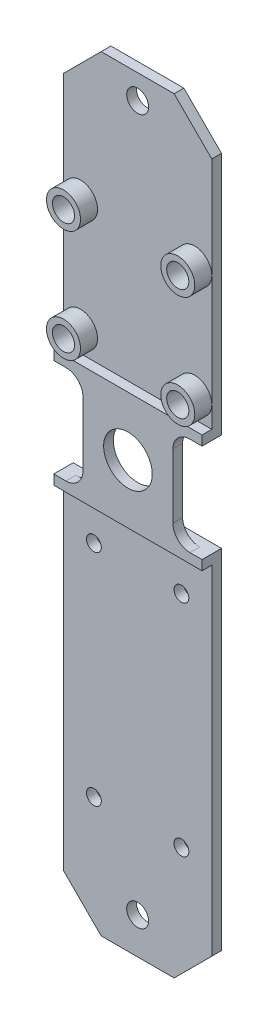
from build123d import *

# Parameters (mm, degrees)
SKETCH_1_W                   = 157.5
SKETCH_1_H                   = 30.5
EXTRUDE_1_DEPTH              = 2
HOLE_WIZARD_4_5_3_05_1_D     = 3.05
HOLE_WIZARD_4_5_3_05_1_DEPTH = 2.5
SKETCH_4_R                   = 3.5
EXTRUDE_2_DEPTH              = 3.5
SKETCH_5_R                   = 2.275
CUT_EXTRUDE_1_DEPTH          = 3.5
SKETCH_6_W                   = 30.5
SKETCH_6_H                   = 20.2
CUT_EXTRUDE_3_DEPTH          = 2.1
SKETCH_9_W                   = 30.5
SKETCH_9_H                   = 24.2
EXTRUDE_6_DEPTH              = 2
SKETCH_12_R                  = 5
CUT_EXTRUDE_4_DEPTH          = 6.5
HOLE_WIZARD_M4_1_D           = 4.5
SKETCH_13_W                  = 6
SKETCH_13_H                  = 20.2
CUT_EXTRUDE_5_DEPTH          = 4.5
FILLET_8_R                   = 3.5
CHAMFER_1_SIZE               = 7.75


with BuildPart() as part:
    # ｽｹｯﾁ1 → ﾎﾞｽ - 押し出し1 (new body)
    with BuildSketch(Plane(origin=(0, 0, 0), x_dir=(0, 1, 0), z_dir=(0, 0, 1))):
        with Locations((78.75, 15.25)):
            Rectangle(SKETCH_1_W, SKETCH_1_H)
    extrude(amount=EXTRUDE_1_DEPTH)

    # Ø4.5 (3.05) 直径の穴1
    with Locations(Plane.XY.offset(2)):
        with Locations((-24.25, 24), (-6.25, 69.2), (-24.25, 69.2), (-6.25, 24)):
            Hole(HOLE_WIZARD_4_5_3_05_1_D / 2, depth=HOLE_WIZARD_4_5_3_05_1_DEPTH)

    # ｽｹｯﾁ4 → ﾎﾞｽ - 押し出し2 (add)
    with BuildSketch(Plane.XY.offset(2)):
        with Locations((-27, 129)):
            Circle(SKETCH_4_R)
        with Locations((-3.5, 129)):
            Circle(SKETCH_4_R)
        with Locations((-3.5, 106)):
            Circle(SKETCH_4_R)
        with Locations((-27, 106)):
            Circle(SKETCH_4_R)
    extrude(amount=EXTRUDE_2_DEPTH)

    # ｽｹｯﾁ5 → ｶｯﾄ - 押し出し1 (cut)
    with BuildSketch(Plane.XY.offset(5.5)):
        with Locations((-27, 129)):
            Circle(SKETCH_5_R)
        with Locations((-3.5, 129)):
            Circle(SKETCH_5_R)
        with Locations((-3.5, 106)):
            Circle(SKETCH_5_R)
        with Locations((-27, 106)):
            Circle(SKETCH_5_R)
    extrude(amount=-CUT_EXTRUDE_1_DEPTH, mode=Mode.SUBTRACT)

    # ｽｹｯﾁ6 → ｶｯﾄ - 押し出し3 (cut)
    with BuildSketch(Plane(origin=(0, 0, 0), x_dir=(1, 0, 0), z_dir=(0, 0, -1))):
        with Locations((-15.25, -89.5)):
            Rectangle(SKETCH_6_W, SKETCH_6_H)
    extrude(amount=-CUT_EXTRUDE_3_DEPTH, mode=Mode.SUBTRACT)

    # ｽｹｯﾁ9 → ﾎﾞｽ - 押し出し6 (add)
    with BuildSketch(Plane.XY.offset(2)):
        with Locations((-15.25, 89.5)):
            Rectangle(SKETCH_9_W, SKETCH_9_H)
    extrude(amount=EXTRUDE_6_DEPTH)

    # ｽｹｯﾁ12 → ｶｯﾄ - 押し出し4 (cut, through all)
    with BuildSketch(Plane.XY.offset(5.5)):
        with Locations((-15.25, 89.5)):
            Circle(SKETCH_12_R)
    extrude(amount=-CUT_EXTRUDE_4_DEPTH, mode=Mode.SUBTRACT)

    # M4 すきま穴1 (through all)
    with Locations(Plane.XY.offset(2)):
        with Locations((-15.25, 152.5), (-15.25, 7.5)):
            Hole(HOLE_WIZARD_M4_1_D / 2)

    # ｽｹｯﾁ13 → ｶｯﾄ - 押し出し5 (cut, through all)
    with BuildSketch(Plane(origin=(0, 0, 2), x_dir=(1, 0, 0), z_dir=(0, 0, -1))):
        with Locations((-3, -89.5)):
            Rectangle(SKETCH_13_W, SKETCH_13_H)
        with Locations((-27.5, -89.5)):
            Rectangle(SKETCH_13_W, SKETCH_13_H)
    extrude(amount=-CUT_EXTRUDE_5_DEPTH, mode=Mode.SUBTRACT)

    # ﾌｨﾚｯﾄ8
    fillet_8_edges = [part.edges().sort_by_distance(p)[0] for p in [
        (-6, 99.6, 3),
        (-6, 79.4, 3),
        (-24.5, 79.4, 3),
        (-24.5, 99.6, 3),
    ]]
    fillet(fillet_8_edges, radius=FILLET_8_R)

    # 面取り1
    chamfer_1_edges = [part.edges().sort_by_distance(p)[0] for p in [
        (0, 157.5, 1),
        (-30.5, 157.5, 1),
        (-30.5, 0, 1),
        (0, 0, 1),
    ]]
    chamfer(chamfer_1_edges, length=CHAMFER_1_SIZE)


solid = part.part
